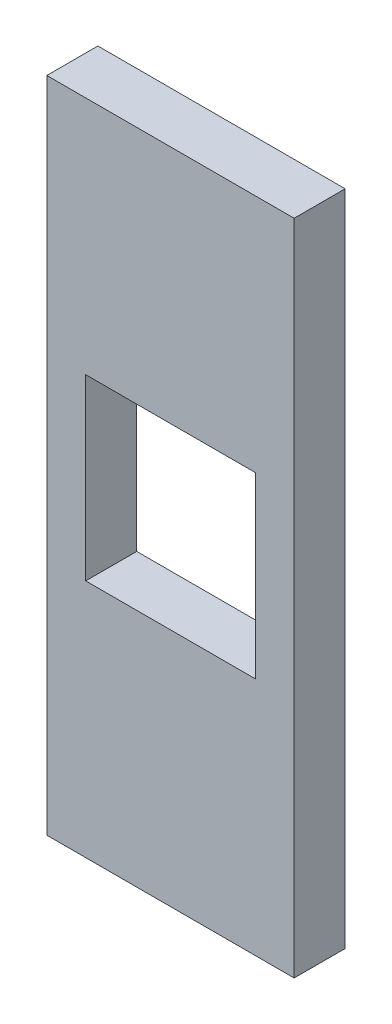
from build123d import *

# Parameters (mm, degrees)
SKETCH1_W           = 17.28
SKETCH1_H           = 18.2
BOSS_EXTRUDE1_DEPTH = 5.2


with BuildPart() as part:
    # Sketch1 → Boss-Extrude1 (new body)
    with BuildSketch(Plane.XY):
        Polygon((-0.1, 66.95), (25.1, 66.95), (25.1, 44.55), (25.1, 39.4), (25.1, 27.45), (25.1, 22.3), (25.1, -0.1), (-0.1, -0.1), (-0.1, 22.3), (-0.1, 27.45), (-0.1, 39.4), (-0.1, 44.55), align=None)
        with Locations((12.5, 33.425)):
            Rectangle(SKETCH1_W, SKETCH1_H, mode=Mode.SUBTRACT)
    extrude(amount=BOSS_EXTRUDE1_DEPTH)


solid = part.part
